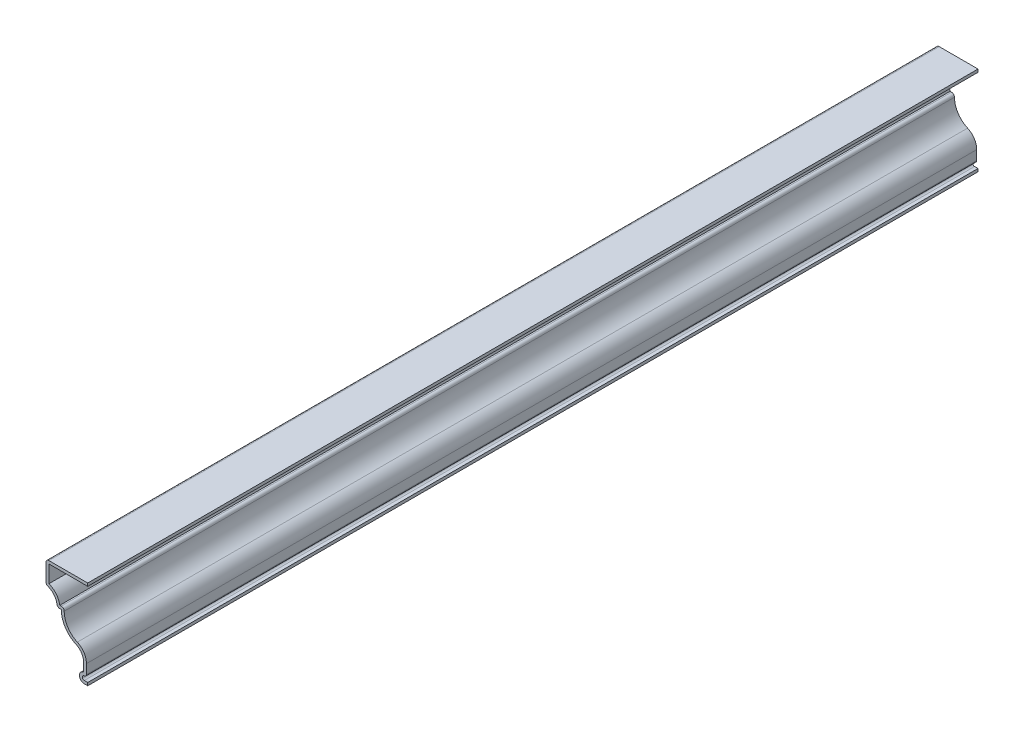
from build123d import *

# Parameters (mm, degrees)
BOSS_EXTRUDE1_DEPTH = 508
FILLET1_R           = 1.651


with BuildPart() as part:
    # Sketch1 → Boss-Extrude1 (new body)
    with BuildSketch(Plane.XY):
        with BuildLine():
            Line((0, 0), (-1.969087929, 0))
            ThreePointArc((-1.969087929, 0), (-4.754845979, 2.586764816), (-2.38125, 5.55625))
            Line((-2.38125, 5.55625), (-2.38125, 10.590485541))
            ThreePointArc((-2.38125, 10.590485541), (-3.532318917, 14.479050507), (-6.614583333, 17.11449036))
            ThreePointArc((-6.614583333, 17.11449036), (-12.779112166, 22.385370067), (-15.08125, 30.1625))
            Line((-15.08125, 30.1625), (-17.4625, 30.1625))
            ThreePointArc((-17.4625, 30.1625), (-19.200240239, 35.281057809), (-23.8125, 38.1))
            Line((-23.8125, 38.1), (-23.8125, 50.8))
            Line((-23.8125, 50.8), (0, 50.8))
            Line((0, 50.8), (0, 49.149))
            Line((0, 49.149), (-22.1615, 49.149))
            Line((-22.1615, 49.149), (-22.1615, 39.348165423))
            ThreePointArc((-22.1615, 39.348165423), (-18.011172085, 36.435510418), (-15.926513678, 31.8135))
            Line((-15.926513678, 31.8135), (-13.321931482, 31.8135))
            ThreePointArc((-13.321931482, 31.8135), (-11.821707612, 23.992793107), (-5.941953704, 18.622260363))
            ThreePointArc((-5.941953704, 18.622260363), (-2.147343733, 15.377741077), (-0.73025, 10.590485541))
            Line((-0.73025, 10.590485541), (-0.73025, 5.174662071))
            ThreePointArc((-0.73025, 5.174662071), (-1.093097229, 4.29867137), (-1.969087929, 3.935824141))
            ThreePointArc((-1.969087929, 3.935824141), (-3.1115, 2.793412071), (-1.969087929, 1.651))
            Line((-1.969087929, 1.651), (0, 1.651))
            Line((0, 1.651), (0, 0))
        make_face()
    extrude(amount=-BOSS_EXTRUDE1_DEPTH)

    # Fillet1
    fillet1_edges = [part.edges().sort_by_distance(p)[0] for p in [
        (-17.4625, 30.1625, -254),
        (-23.8125, 38.1, -254),
        (-23.8125, 50.8, -254),
        (-13.321931482, 31.8135, -254),
    ]]
    fillet(fillet1_edges, radius=FILLET1_R)


solid = part.part
